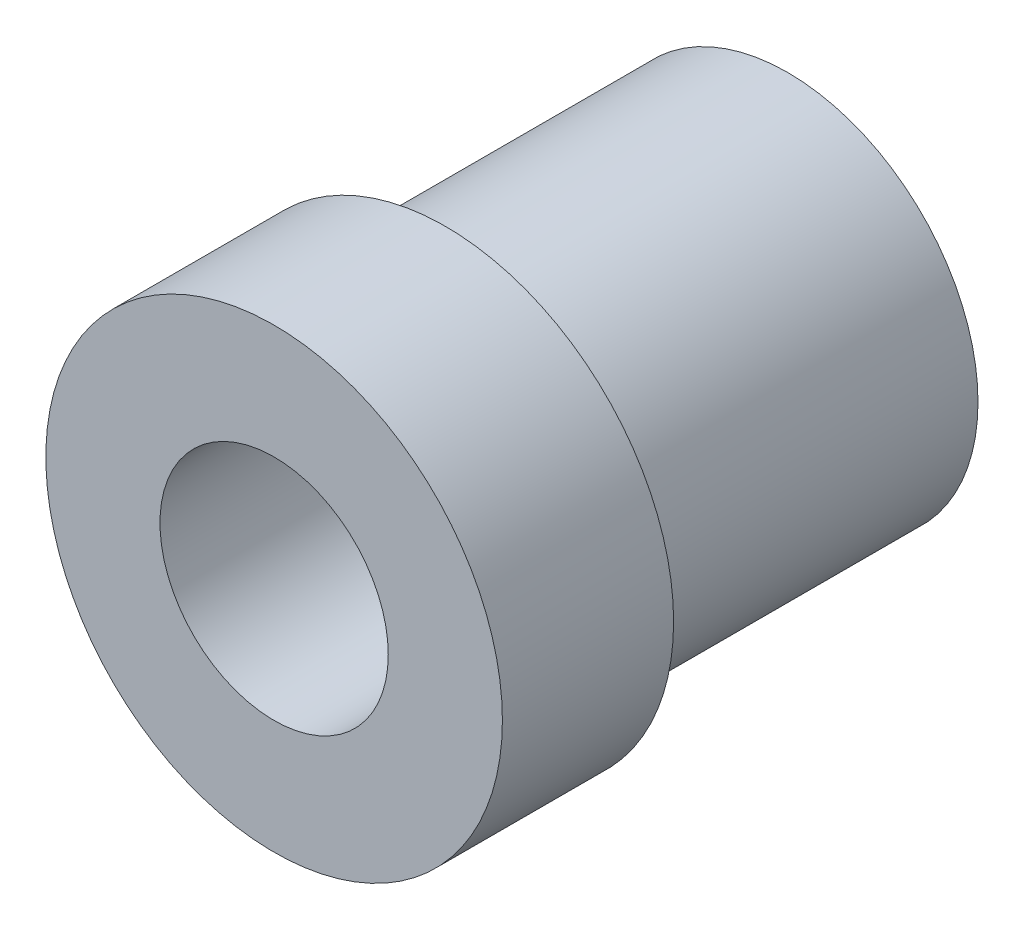
from build123d import *

# Parameters (mm, degrees)
SKETCH1_R           = 5
BOSS_EXTRUDE1_DEPTH = 9
SKETCH2_R           = 6
BOSS_EXTRUDE2_DEPTH = 4.5
SKETCH4_R           = 3
CUT_EXTRUDE1_DEPTH  = 14.5


with BuildPart() as part:
    # Sketch1 → Boss-Extrude1 (new body)
    with BuildSketch(Plane.XY):
        Circle(SKETCH1_R)
    extrude(amount=BOSS_EXTRUDE1_DEPTH)

    # Sketch2 → Boss-Extrude2 (add)
    with BuildSketch(Plane.XY.offset(9)):
        Circle(SKETCH2_R)
    extrude(amount=BOSS_EXTRUDE2_DEPTH)

    # Sketch4 → Cut-Extrude1 (cut, through all)
    with BuildSketch(Plane.XY.offset(13.5)):
        Circle(SKETCH4_R)
    extrude(amount=-CUT_EXTRUDE1_DEPTH, mode=Mode.SUBTRACT)


solid = part.part
